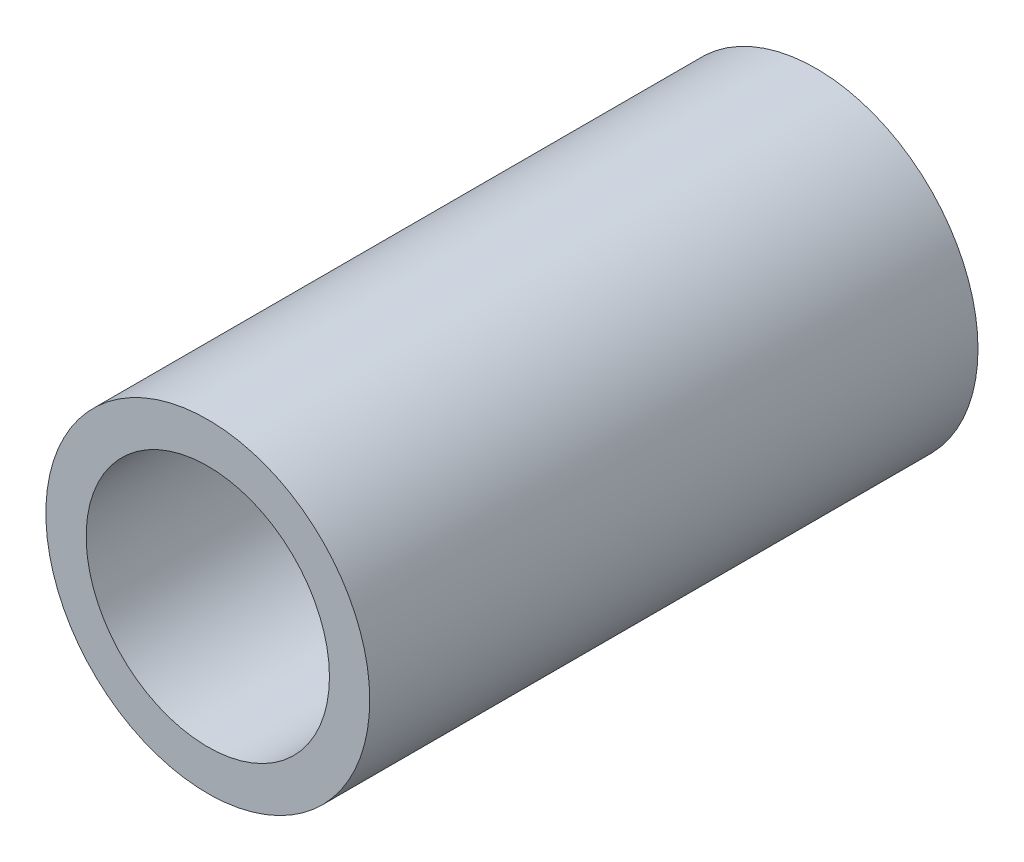
from build123d import *

# Parameters (mm, degrees)
SKIZZE1_R                       = 10.65
SKIZZE1_R_2                     = 8
AUFSATZ_LINEAR_AUSTRAGEN1_DEPTH = 40


with BuildPart() as part:
    # Skizze1 → Aufsatz-Linear austragen1 (new body)
    with BuildSketch(Plane.XY):
        Circle(SKIZZE1_R)
        Circle(SKIZZE1_R_2, mode=Mode.SUBTRACT)
    extrude(amount=AUFSATZ_LINEAR_AUSTRAGEN1_DEPTH)


solid = part.part
